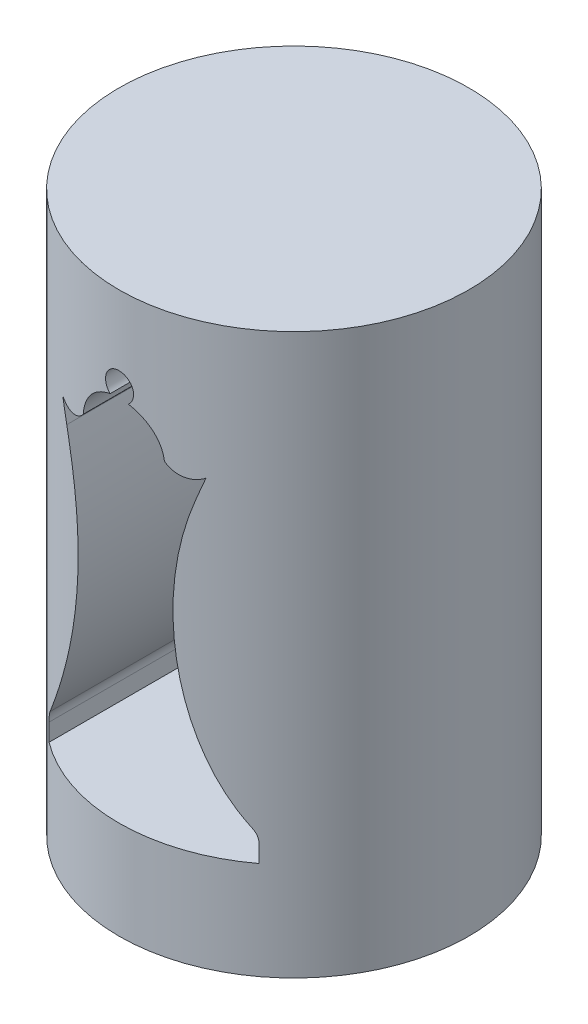
from build123d import *

# Parameters (mm, degrees)
SKETCH2_R               = 12.5
BOSS_EXTRUDE1_DEPTH     = 20
CUT_EXTRUDE1_DEPTH      = 13.5
CUT_EXTRUDE1_DEPTH_BACK = 13.5
SKETCH4_R               = 3
CUT_EXTRUDE2_DEPTH      = 3


with BuildPart() as part:
    # Sketch2 → Boss-Extrude1 (new body, symmetric)
    with BuildSketch(Plane(origin=(0, 0, 0), x_dir=(1, 0, 0), z_dir=(0, 1, 0))):
        Circle(SKETCH2_R)
    extrude(amount=BOSS_EXTRUDE1_DEPTH, both=True)

    # Sketch3 → Cut-Extrude1 (cut, two sides)
    with BuildSketch(Plane.XY) as cut_extrude1_sk:
        with BuildLine():
            Line((-7.5, -13), (7.5, -13))
            Line((7.5, -13), (7.5, -11.75))
            ThreePointArc((7.5, -11.75), (7.429735441, -11.282497399), (7.225150448, -10.856304049))
            ThreePointArc((7.225150448, -10.856304049), (3.577993471, -1.282835033), (4.615823257, 8.909121225))
            Line((4.615823257, 8.909121225), (5.118882067, 10.357861534))
            ThreePointArc((5.118882067, 10.357861534), (3.945658152, 10.08267593), (2.899801007, 10.681311299))
            ThreePointArc((2.899801007, 10.681311299), (2.188817627, 12.324233844), (0.651338796, 13.241212959))
            ThreePointArc((0.651338796, 13.241212959), (0, 15), (-0.651338796, 13.241212959))
            ThreePointArc((-0.651338796, 13.241212959), (-2.188817627, 12.324233844), (-2.899801007, 10.681311299))
            ThreePointArc((-2.899801007, 10.681311299), (-3.945658152, 10.08267593), (-5.118882067, 10.357861534))
            Line((-5.118882067, 10.357861534), (-4.615823257, 8.909121225))
            ThreePointArc((-4.615823257, 8.909121225), (-3.577993471, -1.282835033), (-7.225150448, -10.856304049))
            ThreePointArc((-7.225150448, -10.856304049), (-7.429735441, -11.282497399), (-7.5, -11.75))
            Line((-7.5, -11.75), (-7.5, -13))
        make_face()
    extrude(amount=CUT_EXTRUDE1_DEPTH, mode=Mode.SUBTRACT)
    extrude(cut_extrude1_sk.sketch, amount=-CUT_EXTRUDE1_DEPTH_BACK, mode=Mode.SUBTRACT)

    # Sketch4 → Cut-Extrude2 (cut)
    with BuildSketch(Plane(origin=(0, -20, 0), x_dir=(-1, 0, 0), z_dir=(0, -1, 0))):
        Circle(SKETCH4_R)
    extrude(amount=-CUT_EXTRUDE2_DEPTH, mode=Mode.SUBTRACT)


solid = part.part
